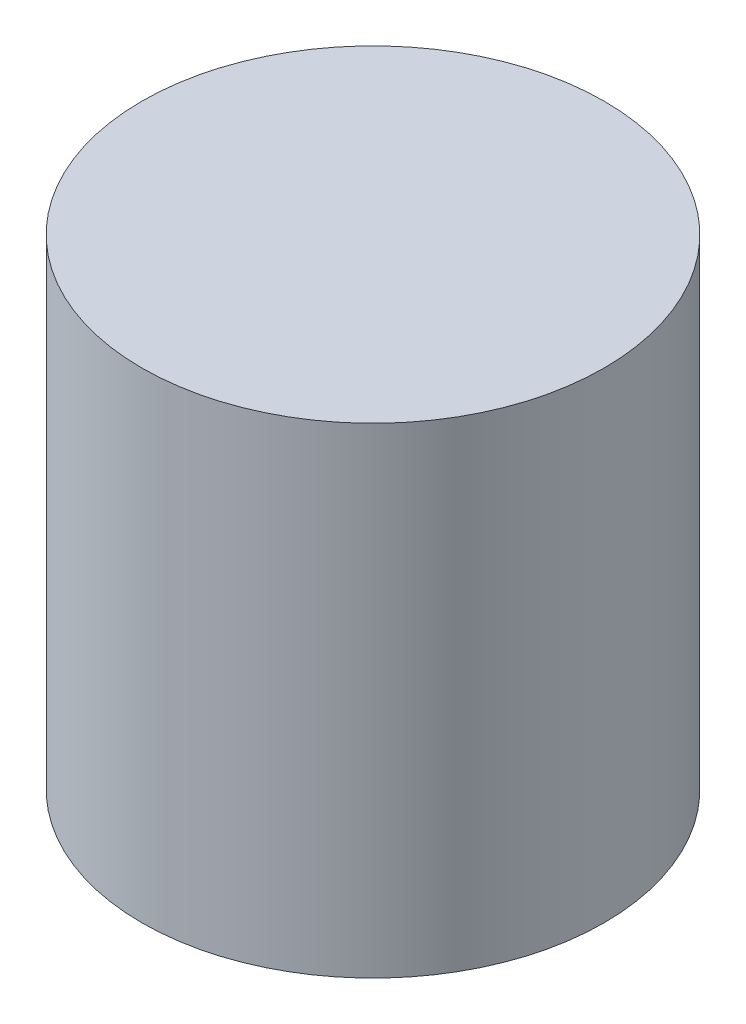
from build123d import *

# Parameters (mm, degrees)
SKETCH1_R           = 38
BOSS_EXTRUDE1_DEPTH = 79
SKETCH9_R           = 36.5
CUT_EXTRUDE1_DEPTH  = 76


with BuildPart() as part:
    # Sketch1 → Boss-Extrude1 (new body)
    with BuildSketch(Plane(origin=(0, 0, 0), x_dir=(1, 0, 0), z_dir=(0, 1, 0))):
        Circle(SKETCH1_R)
    extrude(amount=BOSS_EXTRUDE1_DEPTH)

    # Sketch9 → Cut-Extrude1 (cut)
    with BuildSketch(Plane.XZ):
        Circle(SKETCH9_R)
    extrude(amount=-CUT_EXTRUDE1_DEPTH, mode=Mode.SUBTRACT)


solid = part.part
